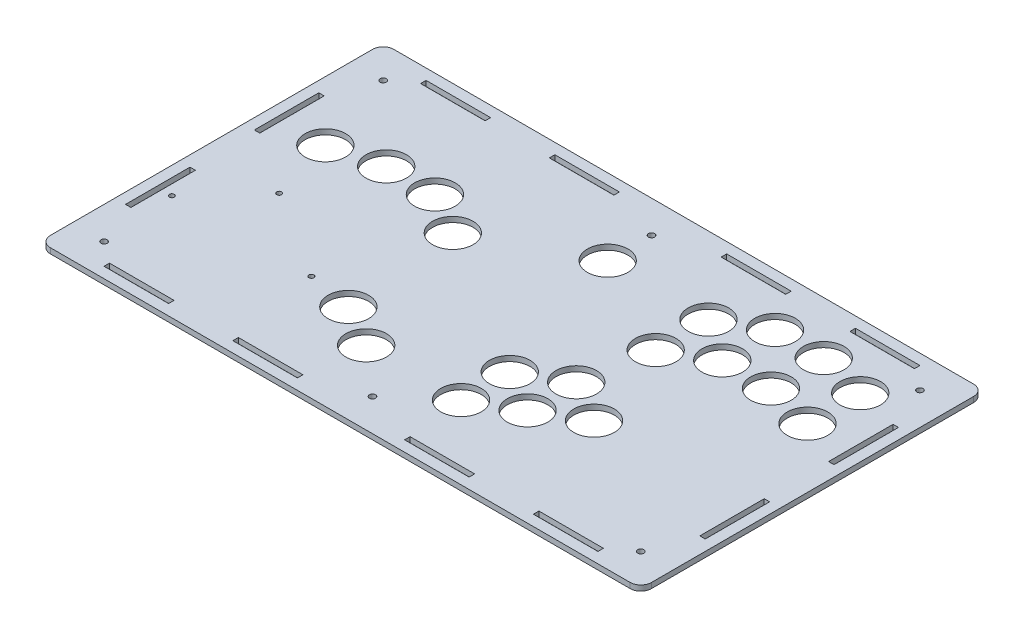
from build123d import *

# Parameters (mm, degrees)
PANEL_PROFILE_2_W        = 355.6
PANEL_PROFILE_2_H        = 203.2
PANEL_PROFILE_DEPTH      = 3.175
RIGHT_BUTTONS_DEPTH      = 205.80595847
RIGHT_BUTTONS_DEPTH_BACK = 3.175
RIGHT_HAND_BUTTONS_R     = 12
SKETCH4_R                = 12
C_STICK_DEPTH            = 3.175
START_BUTTON_R           = 12
START_DEPTH              = 3.175
SKETCH7_R                = 12
L_STICK_DEPTH            = 3.175
SKETCH8_R                = 1.8288
CUT_EXTRUDE1_DEPTH       = 10
FILLET1_R                = 6.35
SKETCH9_W                = 38.18
SKETCH9_H                = 3.25
CUT_EXTRUDE2_DEPTH       = 205.80595847
MIRROR2_COPY_1_SKETCH_W  = 38.18
MIRROR2_COPY_1_SKETCH_H  = 3.25
MIRROR2_COPY_1_DEPTH     = 205.80595847
SKETCH10_W               = 3.2004
SKETCH10_H               = 38.1254
CUT_EXTRUDE3_DEPTH       = 205.80595847
MIRROR4_COPY_1_SKETCH_W  = 3.2004
MIRROR4_COPY_1_SKETCH_H  = 38.1254
MIRROR4_COPY_1_DEPTH     = 205.80595847
CUT_EXTRUDE4_DEPTH       = 205.80595847
CUT_EXTRUDE4_DEPTH_BACK  = 205.80595847
SKETCH12_R               = 1.4732


with BuildPart() as part:
    # Panel Profile 2 → Panel-Profile (new body)
    with BuildSketch(Plane(origin=(0, 0, 0), x_dir=(1, 0, 0), z_dir=(0, 1, 0))):
        Rectangle(PANEL_PROFILE_2_W, PANEL_PROFILE_2_H)
    extrude(amount=-PANEL_PROFILE_DEPTH)

    # Right Hand Buttons → Right Buttons (cut, two sides: drawn at the far end of the back side and taken through both)
    with BuildSketch(Plane(origin=(0, 0, 0), x_dir=(1, 0, 0), z_dir=(0, 1, 0)).offset(-RIGHT_BUTTONS_DEPTH_BACK)):
        with Locations((60, 56.2)):
            Circle(RIGHT_HAND_BUTTONS_R)
        with Locations((85, 70.6)):
            Circle(RIGHT_HAND_BUTTONS_R)
        with Locations((113.8, 70.6)):
            Circle(RIGHT_HAND_BUTTONS_R)
        with Locations((142.6, 63.4)):
            Circle(RIGHT_HAND_BUTTONS_R)
        with Locations((60, 25)):
            Circle(RIGHT_HAND_BUTTONS_R)
        with Locations((85, 39.4)):
            Circle(RIGHT_HAND_BUTTONS_R)
        with Locations((113.8, 39.4)):
            Circle(RIGHT_HAND_BUTTONS_R)
        with Locations((142.6, 32.2)):
            Circle(RIGHT_HAND_BUTTONS_R)
    extrude(amount=RIGHT_BUTTONS_DEPTH + RIGHT_BUTTONS_DEPTH_BACK, mode=Mode.SUBTRACT)

    # Sketch4 → C-Stick (cut)
    with BuildSketch(Plane(origin=(0, 0, 0), x_dir=(1, 0, 0), z_dir=(0, 1, 0))):
        with Locations((53, -43.8)):
            Circle(SKETCH4_R)
        with Locations((53, -15)):
            Circle(SKETCH4_R)
        with Locations((77.941531629, -29.4)):
            Circle(SKETCH4_R)
        with Locations((28.058468371, -29.4)):
            Circle(SKETCH4_R)
        with Locations((28.058468371, -58.2)):
            Circle(SKETCH4_R)
    extrude(amount=-C_STICK_DEPTH, mode=Mode.SUBTRACT)

    # Start Button → Start (cut)
    with BuildSketch(Plane(origin=(0, 0, 0), x_dir=(1, 0, 0), z_dir=(0, 1, 0))):
        with Locations((0, 56.6)):
            Circle(START_BUTTON_R)
    extrude(amount=-START_DEPTH, mode=Mode.SUBTRACT)

    # Sketch7 → L-Stick (cut)
    with BuildSketch(Plane(origin=(0, 0, 0), x_dir=(1, 0, 0), z_dir=(0, 1, 0))):
        with Locations((-142.6, 32.2)):
            Circle(SKETCH7_R)
        with Locations((-113.8, 39.4)):
            Circle(SKETCH7_R)
        with Locations((-85, 39.4)):
            Circle(SKETCH7_R)
        with Locations((-60, 25)):
            Circle(SKETCH7_R)
        with Locations((-53, -43.8)):
            Circle(SKETCH7_R)
        with Locations((-28.058468371, -58.2)):
            Circle(SKETCH7_R)
    extrude(amount=-L_STICK_DEPTH, mode=Mode.SUBTRACT)

    # Sketch8 → Cut-Extrude1 (cut)
    with BuildSketch(Plane(origin=(0, 0, 0), x_dir=(1, 0, 0), z_dir=(0, 1, 0))):
        with Locations((-158.75, 82.55)):
            Circle(SKETCH8_R)
        with Locations((0, 82.55)):
            Circle(SKETCH8_R)
        with Locations((158.75, 82.55)):
            Circle(SKETCH8_R)
        with Locations((-158.75, -82.55)):
            Circle(SKETCH8_R)
        with Locations((0, -82.55)):
            Circle(SKETCH8_R)
        with Locations((158.75, -82.55)):
            Circle(SKETCH8_R)
    extrude(amount=-CUT_EXTRUDE1_DEPTH, mode=Mode.SUBTRACT)

    # Fillet1
    fillet1_edges = [part.edges().sort_by_distance(p)[0] for p in [
        (177.8, -1.5875, -101.6),
        (177.8, -1.5875, 101.6),
        (-177.8, -1.5875, 101.6),
        (-177.8, -1.5875, -101.6),
    ]]
    fillet(fillet1_edges, radius=FILLET1_R)

    # Sketch9 → Cut-Extrude2 (cut, symmetric)
    with BuildSketch(Plane(origin=(0, 0, 0), x_dir=(1, 0, 0), z_dir=(0, 1, 0))):
        with Locations((-127, 93.625)):
            Rectangle(SKETCH9_W, SKETCH9_H)
        with Locations((-50.8, 93.625)):
            Rectangle(SKETCH9_W, SKETCH9_H)
    cut_extrude2 = extrude(amount=CUT_EXTRUDE2_DEPTH, both=True, mode=Mode.SUBTRACT)

    # Mirror1: Cut-Extrude2 across plane
    add(cut_extrude2.mirror(Plane(origin=(0, 0, 0), x_dir=(0, 0, 1), z_dir=(1, 0, 0))), mode=Mode.SUBTRACT)

    # Mirror2: Cut-Extrude2 across plane
    add(cut_extrude2.mirror(Plane.XY), mode=Mode.SUBTRACT)

    # Mirror2 copy 1 sketch → Mirror2 copy 1 (cut, symmetric)
    with BuildSketch(Plane(origin=(0, 0, 0), x_dir=(-1, 0, 0), z_dir=(0, 1, 0))):
        with Locations((-127, 93.625)):
            Rectangle(MIRROR2_COPY_1_SKETCH_W, MIRROR2_COPY_1_SKETCH_H)
        with Locations((-50.8, 93.625)):
            Rectangle(MIRROR2_COPY_1_SKETCH_W, MIRROR2_COPY_1_SKETCH_H)
    extrude(amount=MIRROR2_COPY_1_DEPTH, both=True, mode=Mode.SUBTRACT)

    # Sketch10 → Cut-Extrude3 (cut, symmetric)
    with BuildSketch(Plane(origin=(0, 0, 0), x_dir=(1, 0, 0), z_dir=(0, 1, 0))):
        with Locations((-169.8498, 38.1)):
            Rectangle(SKETCH10_W, SKETCH10_H)
    cut_extrude3 = extrude(amount=CUT_EXTRUDE3_DEPTH, both=True, mode=Mode.SUBTRACT)

    # Mirror3: Cut-Extrude3 across plane
    add(cut_extrude3.mirror(Plane.XY), mode=Mode.SUBTRACT)

    # Mirror4: Cut-Extrude3 across plane
    add(cut_extrude3.mirror(Plane(origin=(0, 0, 0), x_dir=(0, 0, 1), z_dir=(1, 0, 0))), mode=Mode.SUBTRACT)

    # Mirror4 copy 1 sketch → Mirror4 copy 1 (cut, symmetric)
    with BuildSketch(Plane(origin=(0, 0, 0), x_dir=(-1, 0, 0), z_dir=(0, 1, 0))):
        with Locations((-169.8498, 38.1)):
            Rectangle(MIRROR4_COPY_1_SKETCH_W, MIRROR4_COPY_1_SKETCH_H)
    extrude(amount=MIRROR4_COPY_1_DEPTH, both=True, mode=Mode.SUBTRACT)

    # Sketch12 → Cut-Extrude4 (cut, two sides: drawn at the far end of the back side and taken through both)
    with BuildSketch(Plane.XZ.offset(3.175).offset(-CUT_EXTRUDE4_DEPTH_BACK)):
        with Locations((-79.6196, 39.06)):
            Circle(SKETCH12_R)
        with Locations((-131.6896, 6.04)):
            Circle(SKETCH12_R)
        with Locations((-162.1696, 39.06)):
            Circle(SKETCH12_R)
    extrude(amount=CUT_EXTRUDE4_DEPTH + CUT_EXTRUDE4_DEPTH_BACK, mode=Mode.SUBTRACT)


solid = part.part
